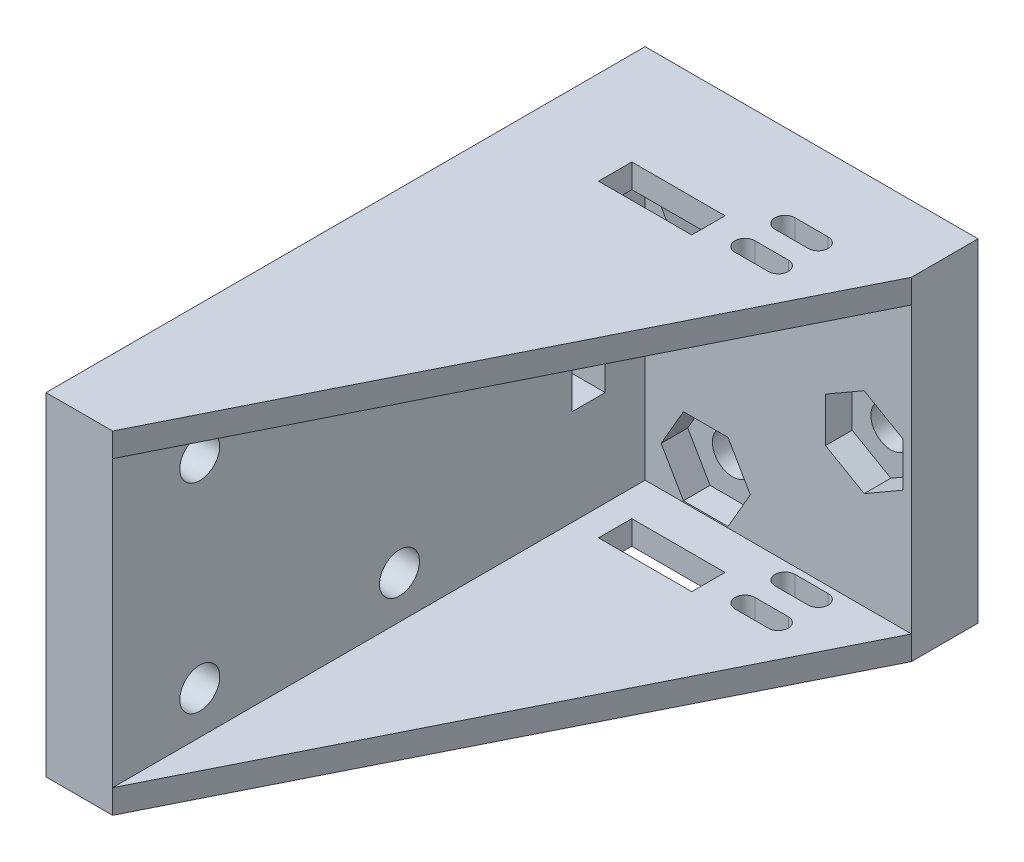
from build123d import *

# Parameters (mm, degrees)
SKETCH1_W           = 25
SKETCH1_H           = 25
SKETCH1_R           = 1.5
BOSS_EXTRUDE1_DEPTH = 5
SKETCH2_W           = 5
SKETCH2_H           = 25
BOSS_EXTRUDE2_DEPTH = 40
CUT_EXTRUDE1_DEPTH  = 2
BOSS_EXTRUDE3_DEPTH = 1.8
BOSS_EXTRUDE4_DEPTH = 1.8
SKETCH6_W           = 7
SKETCH6_H           = 2.5
CUT_EXTRUDE2_DEPTH  = 26
SKETCH7_W           = 2.5
SKETCH7_H           = 7
CUT_EXTRUDE3_DEPTH  = 6
CUT_EXTRUDE4_DEPTH  = 26
SKETCH9_R           = 1.5
CUT_EXTRUDE5_DEPTH  = 26


with BuildPart() as part:
    # Sketch1 → Boss-Extrude1 (new body)
    with BuildSketch(Plane.XY):
        with Locations((-32.675, 0)):
            Rectangle(SKETCH1_W, SKETCH1_H)
        with Locations((-35.625, 7.7)):
            Circle(SKETCH1_R, mode=Mode.SUBTRACT)
        with Locations((-35.625, -7.7)):
            Circle(SKETCH1_R, mode=Mode.SUBTRACT)
        with Locations((-23.725, 0)):
            Circle(SKETCH1_R, mode=Mode.SUBTRACT)
    extrude(amount=BOSS_EXTRUDE1_DEPTH)

    # Sketch2 → Boss-Extrude2 (add)
    with BuildSketch(Plane.XY.offset(5)):
        with Locations((-42.675, 0)):
            Rectangle(SKETCH2_W, SKETCH2_H)
    extrude(amount=BOSS_EXTRUDE2_DEPTH)

    # Sketch3 → Cut-Extrude1 (cut)
    with BuildSketch(Plane.XY.offset(5)):
        Polygon((-37.299315781, 4.8), (-33.950684219, 4.8), (-32.276368439, 7.7), (-33.950684219, 10.6), (-37.299315781, 10.6), (-38.973631561, 7.7), align=None)
        Polygon((-33.950684219, -4.8), (-37.299315781, -4.8), (-38.973631561, -7.7), (-37.299315781, -10.6), (-33.950684219, -10.6), (-32.276368439, -7.7), align=None)
        Polygon((-23.725, -3.348631561), (-20.825, -1.674315781), (-20.825, 1.674315781), (-23.725, 3.348631561), (-26.625, 1.674315781), (-26.625, -1.674315781), align=None)
    extrude(amount=-CUT_EXTRUDE1_DEPTH, mode=Mode.SUBTRACT)

    # Sketch4 → Boss-Extrude3 (add)
    with BuildSketch(Plane.XZ.offset(12.5)):
        Polygon((-40.175, 45), (-20.175, 5), (-40.175, 5), align=None)
    extrude(amount=-BOSS_EXTRUDE3_DEPTH)

    # Sketch5 → Boss-Extrude4 (add)
    with BuildSketch(Plane(origin=(0, 12.5, 0), x_dir=(1, 0, 0), z_dir=(0, 1, 0))):
        Polygon((-40.175, -45), (-20.175, -5), (-40.175, -5), align=None)
    extrude(amount=-BOSS_EXTRUDE4_DEPTH)

    # Sketch6 → Cut-Extrude2 (cut, through all)
    with BuildSketch(Plane(origin=(0, 12.5, 0), x_dir=(1, 0, 0), z_dir=(0, 1, 0))):
        with Locations((-34.675, -9.25)):
            Rectangle(SKETCH6_W, SKETCH6_H)
    extrude(amount=-CUT_EXTRUDE2_DEPTH, mode=Mode.SUBTRACT)

    # Sketch7 → Cut-Extrude3 (cut, through all)
    with BuildSketch(Plane(origin=(-40.175, 0, 0), x_dir=(0, 0, -1), z_dir=(1, 0, 0))):
        with Locations((-9.25, 0)):
            Rectangle(SKETCH7_W, SKETCH7_H)
    extrude(amount=-CUT_EXTRUDE3_DEPTH, mode=Mode.SUBTRACT)

    # Sketch8 → Cut-Extrude4 (cut, through all)
    with BuildSketch(Plane.XZ.offset(12.5)):
        with BuildLine():
            Line((-25.925, 10), (-28.425, 10))
            ThreePointArc((-28.425, 10), (-29.175, 9.25), (-28.425, 8.5))
            Line((-28.425, 8.5), (-25.925, 8.5))
            ThreePointArc((-25.925, 8.5), (-25.175, 9.25), (-25.925, 10))
        make_face()
        with BuildLine():
            Line((-28.425, 5.5), (-25.925, 5.5))
            ThreePointArc((-25.925, 5.5), (-25.175, 6.25), (-25.925, 7))
            Line((-25.925, 7), (-28.425, 7))
            ThreePointArc((-28.425, 7), (-29.175, 6.25), (-28.425, 5.5))
        make_face()
    extrude(amount=-CUT_EXTRUDE4_DEPTH, mode=Mode.SUBTRACT)

    # Sketch9 → Cut-Extrude5 (cut, through all)
    with BuildSketch(Plane.ZY.offset(45.175)):
        with Locations((23.45, 7.5)):
            Circle(SKETCH9_R)
        with Locations((23.45, -7.5)):
            Circle(SKETCH9_R)
        with Locations((38.45, 7.5)):
            Circle(SKETCH9_R)
        with Locations((38.45, -7.5)):
            Circle(SKETCH9_R)
    extrude(amount=-CUT_EXTRUDE5_DEPTH, mode=Mode.SUBTRACT)


solid = part.part
